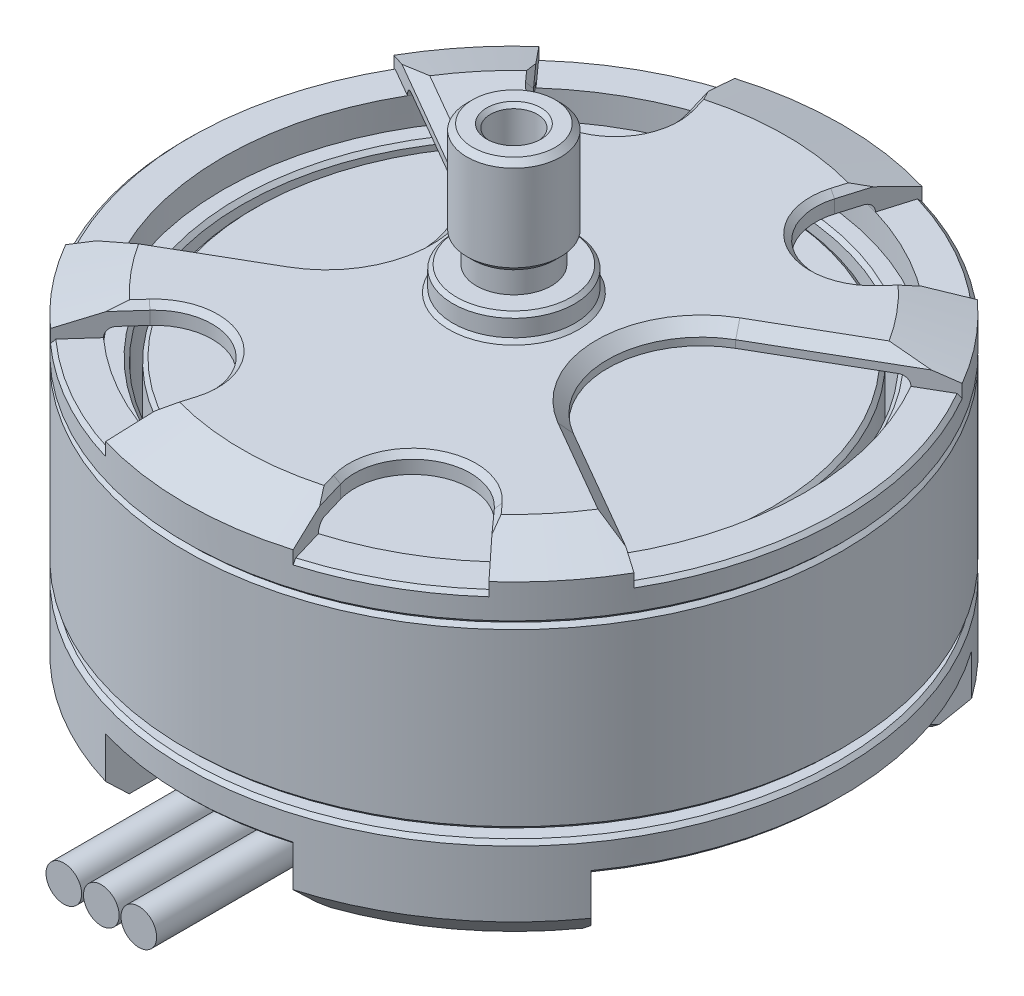
from build123d import *

# Parameters (mm, degrees)
SKETCH2_R          = 1.5
CUT_EXTRUDE4_DEPTH = 3.5
FILLET1_R          = 2
CUT_EXTRUDE5_DEPTH = 1.5
SKETCH4_R          = 1.25
CUT_EXTRUDE6_DEPTH = 3
CHAMFER1_SIZE      = 0.6
CHAMFER2_SIZE      = 0.3
CHAMFER3_SIZE      = 0.2
SWEEP1_PROFILE_R   = 0.95
LPATTERN2_COUNT    = 3
LPATTERN2_PITCH    = 2


with BuildPart() as part:
    # Sketch1 → Revolve1 (revolve)
    with BuildSketch(Plane.XY):
        with BuildLine():
            Line((0.75, 0), (2, 0))
            Line((2, 0), (2, 2))
            Line((2, 2), (5, 2))
            Line((5, 2), (6, 0))
            Line((6, 0), (16, 0))
            Line((16, 0), (17.5, 1.5))
            Line((17.5, 1.5), (17.5, 5.2))
            Line((17.5, 5.2), (16, 5.2))
            Line((16, 5.2), (16, 3.2))
            ThreePointArc((16, 3.2), (15.707106781, 2.492893219), (15, 2.2))
            Line((15, 2.2), (7.5, 2.2))
            ThreePointArc((7.5, 2.2), (6.792893219, 2.492893219), (6.5, 3.2))
            Line((6.5, 3.2), (6.5, 6.2))
            Line((6.5, 6.2), (14, 6.2))
            Line((14, 6.2), (14, 15.2))
            Line((14, 15.2), (3.25, 15.2))
            Line((3.25, 15.2), (3.25, 17.2))
            Line((3.25, 17.2), (15, 17.2))
            ThreePointArc((15, 17.2), (15.353553391, 17.053553391), (15.5, 16.7))
            Line((15.5, 16.7), (15.5, 15.2))
            Line((15.5, 15.2), (14.5, 15.2))
            Line((14.5, 15.2), (14.5, 6.2))
            Line((14.5, 6.2), (16, 6.2))
            Line((16, 6.2), (16, 5.7))
            Line((16, 5.7), (17.5, 5.7))
            Line((17.5, 5.7), (17.5, 15))
            Line((17.5, 15), (17.3, 15.2))
            Line((17.3, 15.2), (17.5, 15.4))
            Line((17.5, 15.4), (17.5, 17.2))
            Line((17.5, 17.2), (14.5, 18.2))
            Line((14.5, 18.2), (3.25, 18.2))
            Line((3.25, 18.2), (3.25, 19.5))
            Line((3.25, 19.5), (2, 19.5))
            Line((2, 19.5), (2, 20.8))
            Line((2, 20.8), (2.5, 20.8))
            Line((2.5, 20.8), (2.5, 26))
            Line((2.5, 26), (0, 26))
            Line((0, 26), (0, 18.2))
            Line((0, 18.2), (0.75, 18.2))
            Line((0.75, 18.2), (0.75, 0))
        make_face()
    revolve(axis=Axis((0, 26, 0), (0, -1, 0)))

    # Sketch2 → Cut-Extrude4 (cut)
    with BuildSketch(Plane.XZ):
        with Locations((8.838834765, 8.838834765)):
            Circle(SKETCH2_R)
        with Locations((6.717514421, -6.717514421)):
            Circle(SKETCH2_R)
        with Locations((-8.838834765, -8.838834765)):
            Circle(SKETCH2_R)
        with Locations((-6.717514421, 6.717514421)):
            Circle(SKETCH2_R)
        with BuildLine():
            Line((-5, 16.770509831), (-5, 8.077747211))
            ThreePointArc((-5, 8.077747211), (0, 9.5), (5, 8.077747211))
            Line((5, 8.077747211), (5, 16.770509831))
            ThreePointArc((5, 16.770509831), (0, 17.5), (-5, 16.770509831))
        make_face()
        with BuildLine():
            Line((14.253887914, 10.152668583), (8.447483902, 4.346264571))
            ThreePointArc((8.447483902, 4.346264571), (9.5, 0), (8.447483902, -4.346264571))
            Line((8.447483902, -4.346264571), (14.253887914, -10.152668583))
            ThreePointArc((14.253887914, -10.152668583), (17.5, 0), (14.253887914, 10.152668583))
        make_face()
        with BuildLine():
            Line((-4.346264571, -8.447483902), (-10.152668583, -14.253887914))
            ThreePointArc((-10.152668583, -14.253887914), (0, -17.5), (10.152668583, -14.253887914))
            Line((10.152668583, -14.253887914), (4.346264571, -8.447483902))
            ThreePointArc((4.346264571, -8.447483902), (0, -9.5), (-4.346264571, -8.447483902))
        make_face()
        with BuildLine():
            Line((-8.447483902, 4.346264571), (-14.253887914, 10.152668583))
            ThreePointArc((-14.253887914, 10.152668583), (-17.5, 0), (-14.253887914, -10.152668583))
            Line((-14.253887914, -10.152668583), (-8.447483902, -4.346264571))
            ThreePointArc((-8.447483902, -4.346264571), (-9.5, 0), (-8.447483902, 4.346264571))
        make_face()
    extrude(amount=-CUT_EXTRUDE4_DEPTH, mode=Mode.SUBTRACT)

    # Fillet1
    fillet1_edges = [part.edges().sort_by_distance(p)[0] for p in [
        (-8.447483902, 1.1, 4.346264571),
        (-8.447483902, 1.1, -4.346264571),
        (-4.346264571, 1.1, -8.447483902),
        (4.346264571, 1.1, -8.447483902),
        (5, 1.1, 8.077747211),
        (-5, 1.1, 8.077747211),
        (8.447483902, 1.1, -4.346264571),
        (8.447483902, 1.1, 4.346264571),
    ]]
    fillet(fillet1_edges, radius=FILLET1_R)

    # Sketch3 → Cut-Extrude5 (cut)
    with BuildSketch(Plane(origin=(0, 18.2, 0), x_dir=(1, 0, 0), z_dir=(0, 1, 0))):
        with BuildLine():
            Line((5, 16.770509831), (3.927007751, 13.17158442))
            ThreePointArc((3.927007751, 13.17158442), (5.376454824, 9.596548001), (9.182221814, 10.227356871))
            Line((9.182221814, 10.227356871), (11.691117506, 13.021819053))
            ThreePointArc((11.691117506, 13.021819053), (8.553450856, 15.267235456), (5, 16.770509831))
        make_face()
        with BuildLine():
            Line((15.155444566, 8.75), (7.5, 4.330127019))
            ThreePointArc((7.5, 4.330127019), (5, 0), (7.5, -4.330127019))
            Line((7.5, -4.330127019), (15.155444566, -8.75))
            ThreePointArc((15.155444566, -8.75), (17.5, 0), (15.155444566, 8.75))
        make_face()
        with BuildLine():
            Line((9.182221814, -10.227356871), (11.691117506, -13.021819053))
            ThreePointArc((11.691117506, -13.021819053), (8.553450856, -15.267235456), (5, -16.770509831))
            Line((5, -16.770509831), (3.927007751, -13.17158442))
            ThreePointArc((3.927007751, -13.17158442), (5.376454824, -9.596548001), (9.182221814, -10.227356871))
        make_face()
        with BuildLine():
            Line((-9.182221814, 10.227356871), (-11.691117506, 13.021819053))
            ThreePointArc((-11.691117506, 13.021819053), (-8.553450856, 15.267235456), (-5, 16.770509831))
            Line((-5, 16.770509831), (-3.927007751, 13.17158442))
            ThreePointArc((-3.927007751, 13.17158442), (-5.376454824, 9.596548001), (-9.182221814, 10.227356871))
        make_face()
        with BuildLine():
            Line((-7.5, -4.330127019), (-15.155444566, -8.75))
            ThreePointArc((-15.155444566, -8.75), (-17.5, 0), (-15.155444566, 8.75))
            Line((-15.155444566, 8.75), (-7.5, 4.330127019))
            ThreePointArc((-7.5, 4.330127019), (-5, 0), (-7.5, -4.330127019))
        make_face()
        with BuildLine():
            Line((-9.182221814, -10.227356871), (-11.691117506, -13.021819053))
            ThreePointArc((-11.691117506, -13.021819053), (-8.553450856, -15.267235456), (-5, -16.770509831))
            Line((-5, -16.770509831), (-3.927007751, -13.17158442))
            ThreePointArc((-3.927007751, -13.17158442), (-5.376454824, -9.596548001), (-9.182221814, -10.227356871))
        make_face()
    extrude(amount=-CUT_EXTRUDE5_DEPTH, mode=Mode.SUBTRACT)

    # Sketch4 → Cut-Extrude6 (cut)
    with BuildSketch(Plane(origin=(0, 26, 0), x_dir=(1, 0, 0), z_dir=(0, 1, 0))):
        Circle(SKETCH4_R)
    extrude(amount=-CUT_EXTRUDE6_DEPTH, mode=Mode.SUBTRACT)

    # Chamfer1
    chamfer1_edges = [part.edges().sort_by_distance(p)[0] for p in [
        (10.028684177, 18.2, -5.790063509),
        (-10.028684177, 18.2, 5.790063509),
        (-5, 18.2, 0),
        (-10.028684177, 18.2, -5.790063509),
        (10.028684177, 18.2, 5.790063509),
        (5, 18.2, 0),
    ]]
    chamfer(chamfer1_edges, length=CHAMFER1_SIZE)

    # Chamfer2
    chamfer2_edges = [part.edges().sort_by_distance(p)[0] for p in [
        (-11.29208457, 0, -7.190865239),
        (-11.29208457, 0, 7.190865239),
        (-8.869693576, 0, -4.328424776),
        (-8.869693576, 0, 4.328424776),
        (-9.5, 0, 0),
        (-5, 0, 13.150242905),
        (5, 0, 13.150242905),
        (-4.215837518, 0, 9.513803189),
        (4.215837518, 0, 9.513803189),
        (0, 0, 9.5),
        (11.29208457, 0, 7.190865239),
        (11.29208457, 0, -7.190865239),
        (8.869693576, 0, 4.328424776),
        (8.869693576, 0, -4.328424776),
        (9.5, 0, 0),
        (7.190865239, 0, -11.29208457),
        (-7.190865239, 0, -11.29208457),
        (4.328424776, 0, -8.869693576),
        (-4.328424776, 0, -8.869693576),
        (0, 0, -9.5),
        (5.217514421, 0, -6.717514421),
        (7.338834765, 0, 8.838834765),
        (-8.217514421, 0, 6.717514421),
        (-10.338834765, 0, -8.838834765),
        (-9.434573874, 18.2, -10.508432043),
        (-4.034932447, 18.2, -13.533574854),
        (-5.376454824, 18.2, -9.596548001),
        (-4.034932447, 18.2, 13.533574854),
        (-9.434573874, 18.2, 10.508432043),
        (-5.376454824, 18.2, 9.596548001),
        (9.434573874, 18.2, 10.508432043),
        (4.034932447, 18.2, 13.533574854),
        (5.376454824, 18.2, 9.596548001),
        (4.034932447, 18.2, -13.533574854),
        (9.434573874, 18.2, -10.508432043),
        (5.376454824, 18.2, -9.596548001),
        (-2.5, 26, 0),
        (-2.5, 20.8, 0),
    ]]
    chamfer(chamfer2_edges, length=CHAMFER2_SIZE)

    # Chamfer3
    chamfer3_edges = [part.edges().sort_by_distance(p)[0] for p in [
        (-17.5, 3.5, 0),
        (0, 3.5, -17.5),
        (0, 3.5, 17.5),
        (16.668728783, 3.5, 5.329491604),
        (-2, 0, 0),
        (-0.75, 0, 0),
        (-8.553450856, 16.7, 15.267235456),
        (-3.25, 19.5, 0),
        (-3.25, 18.2, 0),
        (-17.5, 16.7, 0),
        (-8.553450856, 16.7, -15.267235456),
        (-17.5, 5.7, 0),
        (16.90370196, 16.7, 4.529333289),
        (8.553450856, 16.7, -15.267235456),
        (-14.5, 6.2, 0),
        (-14.5, 15.2, 0),
        (8.553450856, 16.7, 15.267235456),
        (-14, 15.2, 0),
        (-14, 6.2, 0),
        (-1.25, 26, 0),
        (-17.5, 5.2, 0),
    ]]
    chamfer(chamfer3_edges, length=CHAMFER3_SIZE)


with BuildPart() as body_2:
    # Sweep1: sweep along a path in Sketch5
    with BuildLine(Plane(origin=(2, 0, 0), x_dir=(0, 0, -1), z_dir=(1, 0, 0))) as sweep1_path:
        Line((-6.9, 4.6), (-9.2, 4.6))
        ThreePointArc((-9.2, 4.6), (-10.189949494, 4.189949494), (-10.6, 3.2))
        Line((-10.6, 3.2), (-10.6, 2.3))
        ThreePointArc((-10.6, 2.3), (-11.010050506, 1.310050506), (-12, 0.9))
        Line((-12, 0.9), (-22, 0.9))
    # Sweep1 profile (on start of the path) → Sweep1 (sweep)
    with BuildSketch(Plane(origin=(2, 4.6, 6.9), x_dir=(0, 1, 0), z_dir=(0, 0, 1))):
        Circle(SWEEP1_PROFILE_R)
    sweep(path=sweep1_path.line)


with BuildPart() as lpattern2_1:
    # LPattern2: pattern copy
    add(body_2.part.moved(Location(Vector(-1, 0, 0) * (1 * LPATTERN2_PITCH))))


with BuildPart() as lpattern2_2:
    # LPattern2: pattern copy
    add(body_2.part.moved(Location(Vector(-1, 0, 0) * (2 * LPATTERN2_PITCH))))


solid = Compound([part.part, body_2.part, lpattern2_1.part, lpattern2_2.part])
